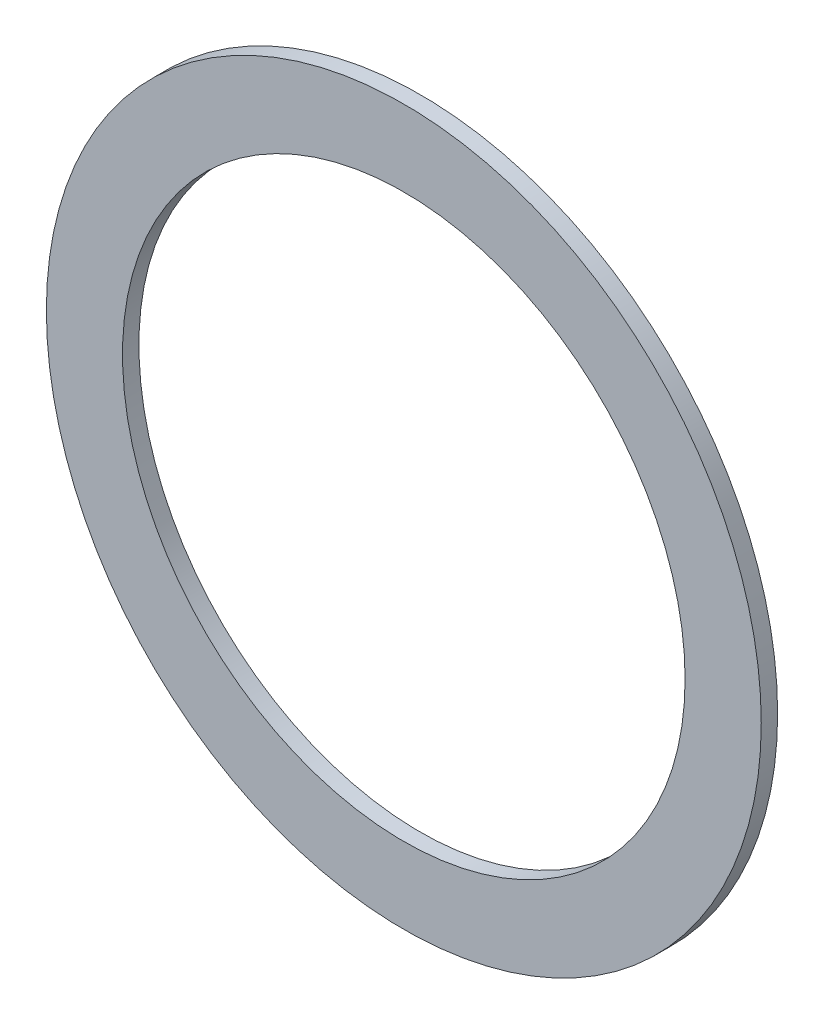
from build123d import *

# Parameters (mm, degrees)
SKETCH1_R           = 11.0871
SKETCH1_R_2         = 8.7249
BOSS_EXTRUDE1_DEPTH = 0.508


with BuildPart() as part:
    # Sketch1 → Boss-Extrude1 (new body)
    with BuildSketch(Plane.XY):
        Circle(SKETCH1_R)
        Circle(SKETCH1_R_2, mode=Mode.SUBTRACT)
    extrude(amount=BOSS_EXTRUDE1_DEPTH)


solid = part.part
